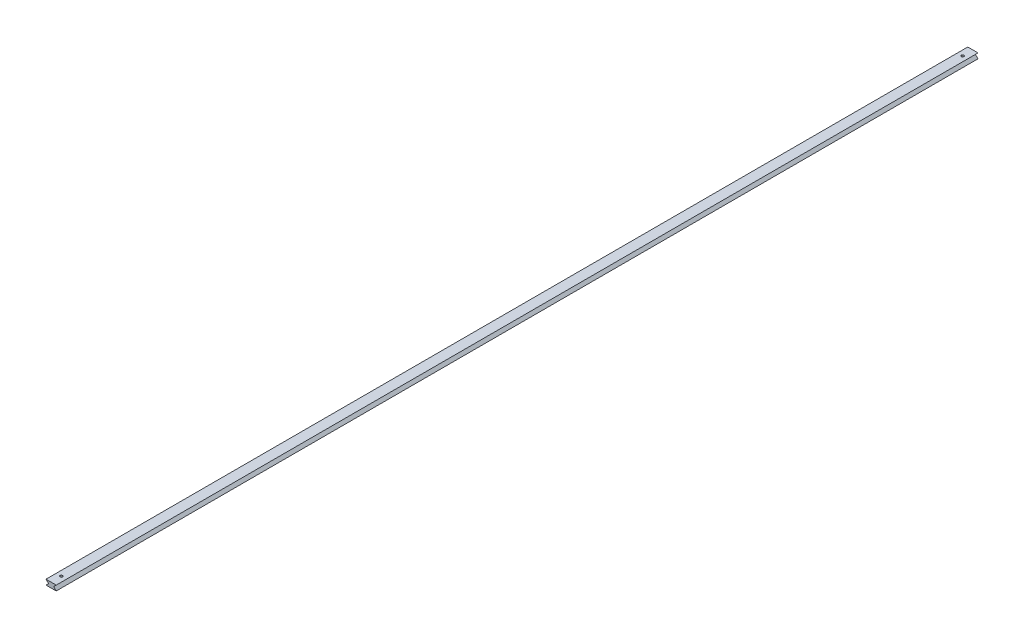
from build123d import *

# Parameters (mm, degrees)
Y_KSEKLIK_EKSTR_ZYON1_DEPTH = 1800
IZIM2_R                     = 2.5
KES_EKSTR_ZYON5_DEPTH       = 10


with BuildPart() as part:
    # Çizim1 → Yükseklik-Ekstrüzyon1 (new body)
    with BuildSketch(Plane.XY):
        Polygon((0, 0), (20, 0), (15, -5), (20, -10), (0, -10), (5, -5), align=None)
    extrude(amount=Y_KSEKLIK_EKSTR_ZYON1_DEPTH)

    # Çizim2 → Kes-Ekstrüzyon5 (cut)
    with BuildSketch(Plane(origin=(0, 0, 0), x_dir=(1, 0, 0), z_dir=(0, 1, 0))):
        with Locations((10, -20)):
            Circle(IZIM2_R)
        with Locations((10, -1780)):
            Circle(IZIM2_R)
    extrude(amount=-KES_EKSTR_ZYON5_DEPTH, mode=Mode.SUBTRACT)


solid = part.part
